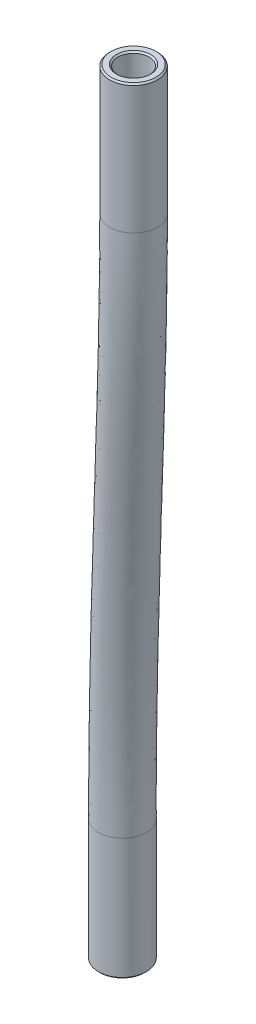
from build123d import *

# Parameters (mm, degrees)
SKETCH1_R     = 2
SKETCH1_R_2   = 1.3
CHAMFER1_SIZE = 0.127


with BuildPart() as part:
    # Sweep1: sweep along a curve in space
    with BuildLine() as sweep1_path:
        Line((-150.085279081, -93.282256564, -9.525), (-150.085279081, -103.482256564, -9.525))
        add(Edge.make_bspline(
            [(-146.727574012, -46.6, -7.098511382), (-146.727574012, -53.268773691, -7.098511382), (-148.406426547, -68.804947167, -8.311755691), (-150.085279081, -84.313023079, -9.525), (-150.085279081, -93.282256564, -9.525)],
            knots=[0, 0, 0, 0, 0.426886099, 1, 1, 1, 1], degree=3))
        Line((-146.727574012, -35.8, -7.098511382), (-146.727574012, -46.6, -7.098511382))
    # Sketch1 → Sweep1 (sweep)
    with BuildSketch(Plane(origin=(0, -95.382256564, 0), x_dir=(1, 0, 0), z_dir=(0, 1, 0))):
        with Locations((-150.085279081, 9.525)):
            Circle(SKETCH1_R)
        with Locations((-150.085279081, 9.525)):
            Circle(SKETCH1_R_2, mode=Mode.SUBTRACT)
    sweep(path=sweep1_path.line)

    # Chamfer1
    chamfer1_edges = [part.edges().sort_by_distance(p)[0] for p in [
        (-148.027574012, -35.8, -7.098511382),
        (-148.727574012, -35.8, -7.098511382),
        (-151.385279081, -103.482256564, -9.525),
        (-152.085279081, -103.482256564, -9.525),
    ]]
    chamfer(chamfer1_edges, length=CHAMFER1_SIZE)


solid = part.part
